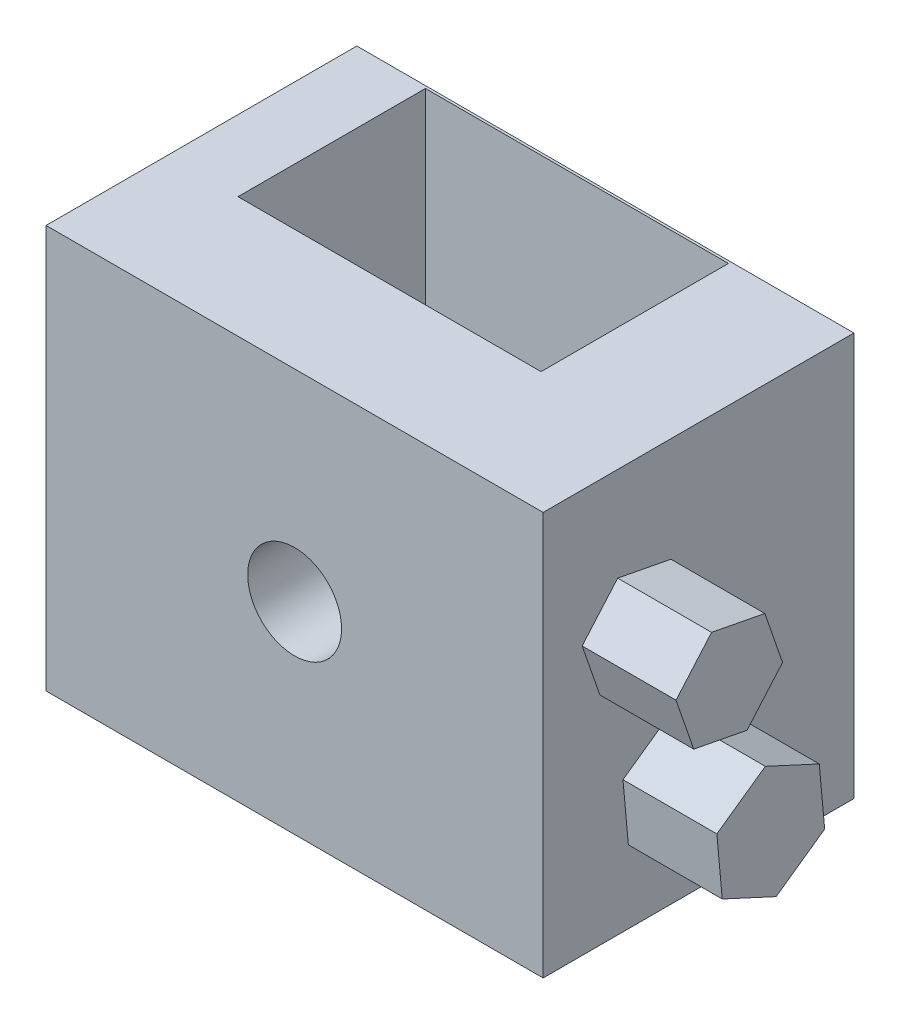
from build123d import *

# Parameters (mm, degrees)
SKETCH2_W           = 134.477697302
SKETCH2_H           = 109.076354478
BOSS_EXTRUDE1_DEPTH = 84.074
SKETCH3_R           = 12.7
CUT_EXTRUDE1_DEPTH  = 127
SKETCH4_W           = 81.978128355
SKETCH4_H           = 50.707128689
CUT_EXTRUDE2_DEPTH  = 104.14
BOSS_EXTRUDE2_DEPTH = 25.4
BOSS_EXTRUDE3_DEPTH = 25.4


with BuildPart() as part:
    # Sketch2 → Boss-Extrude1 (new body)
    with BuildSketch(Plane.XY):
        Rectangle(SKETCH2_W, SKETCH2_H)
    extrude(amount=BOSS_EXTRUDE1_DEPTH)

    # Sketch3 → Cut-Extrude1 (cut)
    with BuildSketch(Plane.XY.offset(84.074)):
        Circle(SKETCH3_R)
    extrude(amount=-CUT_EXTRUDE1_DEPTH, mode=Mode.SUBTRACT)

    # Sketch4 → Cut-Extrude2 (cut)
    with BuildSketch(Plane(origin=(0, 54.538177239, 0), x_dir=(1, 0, 0), z_dir=(0, 1, 0))):
        with Locations((-7.023947617, -26.021677284)):
            Rectangle(SKETCH4_W, SKETCH4_H)
    extrude(amount=-CUT_EXTRUDE2_DEPTH, mode=Mode.SUBTRACT)

    # Sketch5 → Boss-Extrude2 (add)
    with BuildSketch(Plane(origin=(67.238848651, 0, 0), x_dir=(0, 0, -1), z_dir=(1, 0, 0))):
        Polygon((-54.326321663, 1.325818935), (-44.711130396, 12.412030691), (-49.504475775, 26.282136468), (-63.913012421, 29.06603049), (-73.528203689, 17.979818734), (-68.734858309, 4.109712956), align=None)
    extrude(amount=BOSS_EXTRUDE2_DEPTH)

    # Sketch6 → Boss-Extrude3 (add)
    with BuildSketch(Plane(origin=(67.238848651, 0, 0), x_dir=(0, 0, -1), z_dir=(1, 0, 0))):
        Polygon((-33.317190853, -32.329584791), (-34.779908073, -16.333922758), (-49.363916354, -9.602842013), (-62.485207415, -18.867423301), (-61.022490195, -34.863085333), (-46.438481914, -41.594166078), align=None)
    extrude(amount=BOSS_EXTRUDE3_DEPTH)


solid = part.part
